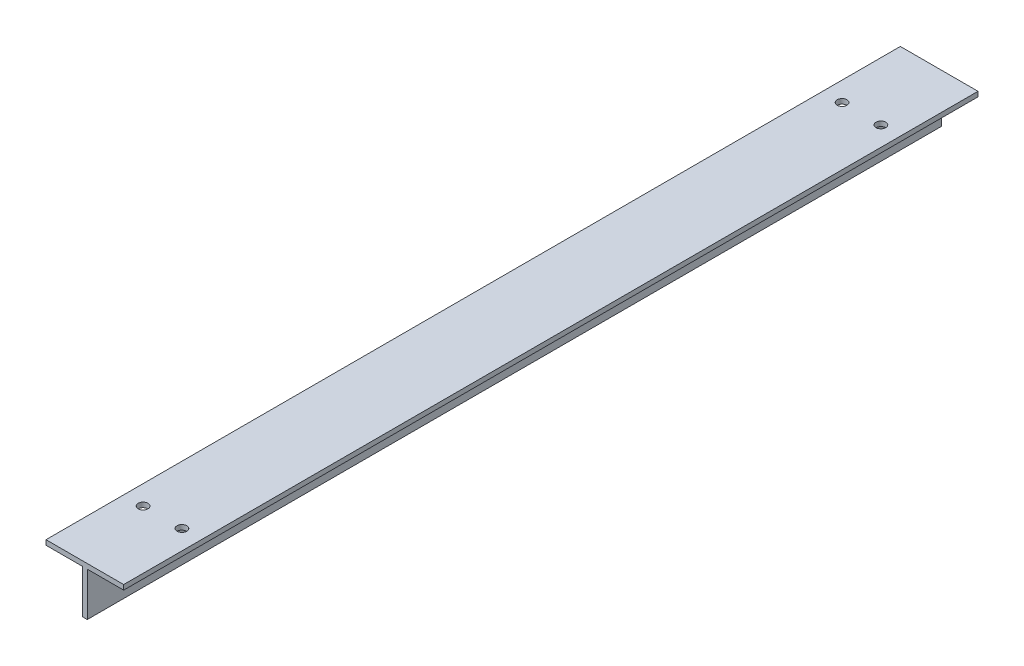
from build123d import *

# Parameters (mm, degrees)
BOSS_EXTRUDE1_DEPTH = 279.4
SKETCH2_R           = 3.5
CUT_EXTRUDE1_DEPTH  = 27.9875
SKETCH3_R           = 3.175
CUT_EXTRUDE2_DEPTH  = 32.75


with BuildPart() as part:
    # Sketch1 → Boss-Extrude1 (new body, symmetric)
    with BuildSketch(Plane.XY):
        Polygon((-25.4, 31.75), (-25.4, 28.575), (-1.5875, 28.575), (-1.5875, 0), (1.5875, 0), (1.5875, 28.575), (25.4, 28.575), (25.4, 31.75), align=None)
    extrude(amount=BOSS_EXTRUDE1_DEPTH, both=True)

    # Sketch2 → Cut-Extrude1 (cut, through all)
    with BuildSketch(Plane(origin=(1.5875, 0, 0), x_dir=(0, 0, -1), z_dir=(1, 0, 0))):
        with Locations((-254, 15.875)):
            Circle(SKETCH2_R)
        with Locations((254, 15.875)):
            Circle(SKETCH2_R)
    extrude(amount=-CUT_EXTRUDE1_DEPTH, mode=Mode.SUBTRACT)

    # Sketch3 → Cut-Extrude2 (cut, through all)
    with BuildSketch(Plane(origin=(0, 31.75, 0), x_dir=(1, 0, 0), z_dir=(0, 1, 0))):
        with Locations((-12.7, 228.6)):
            Circle(SKETCH3_R)
        with Locations((12.7, 228.6)):
            Circle(SKETCH3_R)
        with Locations((12.7, -228.6)):
            Circle(SKETCH3_R)
        with Locations((-12.7, -228.6)):
            Circle(SKETCH3_R)
    extrude(amount=-CUT_EXTRUDE2_DEPTH, mode=Mode.SUBTRACT)


solid = part.part
